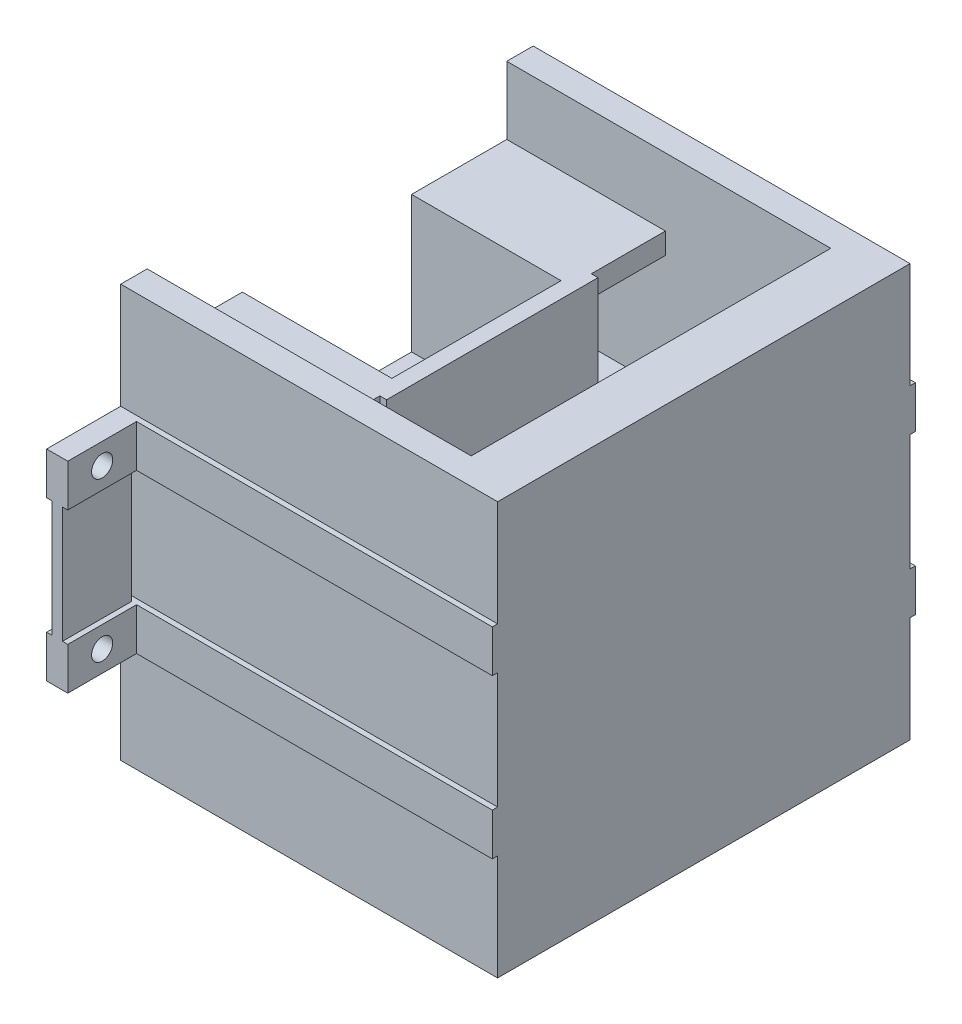
from build123d import *
from build123d.topology import SkipClean

# Parameters (mm, degrees)
SKETCH1_R               = 100
BOSS_EXTRUDE1_DEPTH     = 10
SKETCH2_R               = 95
SKETCH2_R_2             = 80
CUT_EXTRUDE1_DEPTH      = 2
BOSS_EXTRUDE2_DEPTH     = 40
BOSS_EXTRUDE3_DEPTH     = 5
CUT_EXTRUDE2_START      = -5
SKETCH5_W               = 50
SKETCH5_H               = 40
CUT_EXTRUDE2_DEPTH      = 40
BOSS_EXTRUDE4_DEPTH     = 45
SKETCH8_W               = 40
SKETCH8_H               = 5
BOSS_EXTRUDE5_DEPTH     = 55
CUT_EXTRUDE3_START      = -10
SKETCH10_W              = 8.429508811
SKETCH10_H              = 40
CUT_EXTRUDE3_DEPTH      = 10
BOSS_EXTRUDE6_START     = 18.2
BOSS_EXTRUDE6_DEPTH     = 2
BOSS_EXTRUDE7_START     = 18.1
BOSS_EXTRUDE7_DEPTH     = 15
SKETCH13_W              = 20.653307815
SKETCH13_H              = 40
CUT_EXTRUDE4_DEPTH      = 5
BOSS_EXTRUDE8_DEPTH     = 17
BOSS_EXTRUDE9_DEPTH     = 3
BOSS_EXTRUDE10_DEPTH    = 3
SKETCH18_W              = 11.98170237
SKETCH18_H              = 40
CUT_EXTRUDE5_DEPTH      = 5
CUT_EXTRUDE6_START      = -20
CUT_EXTRUDE6_DEPTH      = 25
CUT_EXTRUDE7_DEPTH      = 300
CUT_EXTRUDE7_DEPTH_BACK = 300
BOSS_EXTRUDE12_DEPTH    = 30.7
CUT_EXTRUDE8_DEPTH      = 40
BOSS_EXTRUDE13_START    = -33.64
SKETCH27_W              = 7
SKETCH27_H              = 5
BOSS_EXTRUDE13_DEPTH    = 2
CUT_EXTRUDE9_DEPTH      = 40
F_2_0MM_DOWEL_HOLE2_D   = 2
SKETCH31_W              = 0.5
SKETCH31_H              = 16
CUT_EXTRUDE10_DEPTH     = 12.9
CUT_EXTRUDE11_DEPTH     = 20
SKETCH33_W              = 7
SKETCH33_H              = 2
BOSS_EXTRUDE14_DEPTH    = 15
BOSS_EXTRUDE15_START    = -0.5
SKETCH34_W              = 6.5
SKETCH34_H              = 11
BOSS_EXTRUDE15_DEPTH    = 1
BOSS_EXTRUDE16_DEPTH    = 15.1


with BuildPart() as part:
    # Sketch1 → Boss-Extrude1 (new body)
    with BuildSketch(Plane(origin=(0, 0, 0), x_dir=(1, 0, 0), z_dir=(0, 1, 0))):
        with Locations(Location((0, 0, 0), (0, 0, 270))):
            Circle(SKETCH1_R)
    extrude(amount=BOSS_EXTRUDE1_DEPTH)

    # Sketch2 → Cut-Extrude1 (cut)
    with BuildSketch(Plane(origin=(0, 10, 0), x_dir=(1, 0, 0), z_dir=(0, 1, 0))):
        with Locations(Location((0, 0, 0), (0, 0, 270))):
            Circle(SKETCH2_R)
        with Locations(Location((0, 0, 0), (0, 0, 270))):
            Circle(SKETCH2_R_2, mode=Mode.SUBTRACT)
    extrude(amount=-CUT_EXTRUDE1_DEPTH, mode=Mode.SUBTRACT)

    # Sketch3 → Boss-Extrude2 (add)
    with SkipClean():  # the faces are left unmerged after this step: merging them gives an invalid solid
        with BuildSketch(Plane(origin=(0, 10, 0), x_dir=(1, 0, 0), z_dir=(0, 1, 0))):
            with BuildLine():
                Line((-67.175144213, 67.175144213), (-70.710678119, 70.710678119))
                ThreePointArc((-70.710678119, 70.710678119), (100, 0), (-70.710678119, -70.710678119))
                Line((-70.710678119, -70.710678119), (-67.175144213, -67.175144213))
                ThreePointArc((-67.175144213, -67.175144213), (95, 0), (-67.175144213, 67.175144213))
            make_face()
        extrude(amount=BOSS_EXTRUDE2_DEPTH)

    # Sketch5 → Cut-Extrude2 (cut)
    with SkipClean():  # the faces are left unmerged after this step: merging them gives an invalid solid
        with BuildSketch(Plane(origin=(0, 55, 0), x_dir=(1, 0, 0), z_dir=(0, 1, 0)).offset(CUT_EXTRUDE2_START)):
            with Locations((102.459666924, 0)):
                Rectangle(SKETCH5_W, SKETCH5_H)
        extrude(amount=-CUT_EXTRUDE2_DEPTH, mode=Mode.SUBTRACT)



with BuildPart() as body_2:
    # Sketch4 → Boss-Extrude3 (new body)
    with BuildSketch(Plane(origin=(0, 50, 0), x_dir=(1, 0, 0), z_dir=(0, 1, 0))):
        with BuildLine():
            ThreePointArc((-67.175144213, -67.175144213), (95, 0), (-67.175144213, 67.175144213))
            Line((-67.175144213, 67.175144213), (-56.568542495, 56.568542495))
            ThreePointArc((-56.568542495, 56.568542495), (30.614674589, 73.910362601), (80, 0))
            ThreePointArc((80, 0), (30.614674589, -73.910362601), (-56.568542495, -56.568542495))
            Line((-56.568542495, -56.568542495), (-67.175144213, -67.175144213))
        make_face()
        with BuildLine():
            Line((-70.710678119, 70.710678119), (-67.175144213, 67.175144213))
            ThreePointArc((-67.175144213, 67.175144213), (95, 0), (-67.175144213, -67.175144213))
            Line((-67.175144213, -67.175144213), (-70.710678119, -70.710678119))
            ThreePointArc((-70.710678119, -70.710678119), (100, 0), (-70.710678119, 70.710678119))
        make_face()
    extrude(amount=BOSS_EXTRUDE3_DEPTH)


with BuildPart() as part_1:
    with SkipClean():  # the faces are left unmerged after this step: merging them gives an invalid solid
        add(part.part)

        add(body_2.part)  # Boss-Extrude4 merges body 2
        # Sketch7 → Boss-Extrude4 (add)
        with BuildSketch(Plane(origin=(0, 55, 0), x_dir=(1, 0, 0), z_dir=(0, 1, 0))):
            with BuildLine():
                ThreePointArc((96.824583655, 25), (97.434164903, 22.507410108), (97.979589711, 20))
                Line((97.979589711, 20), (127.459666924, 20))
                Line((127.459666924, 20), (127.459666924, -20))
                Line((127.459666924, -20), (97.979589711, -20))
                ThreePointArc((97.979589711, -20), (97.434164903, -22.507410108), (96.824583655, -25))
                Line((96.824583655, -25), (132.459666924, -25))
                Line((132.459666924, -25), (132.459666924, 25))
                Line((132.459666924, 25), (96.824583655, 25))
            make_face()
        extrude(amount=-BOSS_EXTRUDE4_DEPTH)

    # Sketch8 → Boss-Extrude5 (add)
    with SkipClean():  # the faces are left unmerged after this step: merging them gives an invalid solid
        with BuildSketch(Plane.ZY.offset(-127.459666924)):
            with Locations((0, 12.5)):
                Rectangle(SKETCH8_W, SKETCH8_H)
        extrude(amount=BOSS_EXTRUDE5_DEPTH)

    # Sketch10 → Cut-Extrude3 (cut)
    with SkipClean():  # the faces are left unmerged after this step: merging them gives an invalid solid
        with BuildSketch(Plane.XZ.offset(CUT_EXTRUDE3_START)):
            with Locations((88.6561237, 0)):
                Rectangle(SKETCH10_W, SKETCH10_H)
            with BuildLine():
                Line((92.870878105, -20), (92.870878105, 20))
                ThreePointArc((92.870878105, 20), (95, 0), (92.870878105, -20))
            make_face()
        extrude(amount=-CUT_EXTRUDE3_DEPTH, mode=Mode.SUBTRACT)

    # Sketch13 → Cut-Extrude4 (cut)
    with SkipClean():  # the faces are left unmerged after this step: merging them gives an invalid solid
        with BuildSketch(Plane(origin=(0, 55, 0), x_dir=(1, 0, 0), z_dir=(0, 1, 0))):
            with Locations((100.326653908, 0)):
                Rectangle(SKETCH13_W, SKETCH13_H)
        extrude(amount=-CUT_EXTRUDE4_DEPTH, mode=Mode.SUBTRACT)



with BuildPart() as body_2_2:
    # Sketch11 → Boss-Extrude6 (new body)
    with BuildSketch(Plane(origin=(0, 15, 0), x_dir=(1, 0, 0), z_dir=(0, 1, 0)).offset(BOSS_EXTRUDE6_START)):
        with BuildLine():
            Line((110.459666924, 8), (95.459666924, 8))
            Line((95.459666924, 8), (95.459666924, 3.5))
            Line((95.459666924, 3.5), (100.359666924, 3.5))
            ThreePointArc((100.359666924, 3.5), (103.859666924, 0), (100.359666924, -3.5))
            Line((100.359666924, -3.5), (95.459666924, -3.5))
            Line((95.459666924, -3.5), (95.459666924, -8))
            Line((95.459666924, -8), (110.459666924, -8))
            Line((110.459666924, -8), (110.459666924, 8))
        make_face()
    extrude(amount=BOSS_EXTRUDE6_DEPTH)

    # Sketch12 → Boss-Extrude7 (add)
    with BuildSketch(Plane(origin=(0, 15, 0), x_dir=(1, 0, 0), z_dir=(0, 1, 0)).offset(BOSS_EXTRUDE7_START)):
        Polygon((95.459666924, -10), (95.459666924, -8), (110.459666924, -8), (110.459666924, 8), (95.459666924, 8), (95.459666924, 10), (112.459666924, 10), (112.459666924, -10), align=None)
    extrude(amount=BOSS_EXTRUDE7_DEPTH)


with BuildPart() as part_2:
    with SkipClean():  # the faces are left unmerged after this step: merging them gives an invalid solid
        add(part_1.part)

        add(body_2_2.part)  # Boss-Extrude8 merges body 2 2
        # Sketch15 → Boss-Extrude8 (add)
        with BuildSketch(Plane(origin=(112.459666924, 0, 0), x_dir=(0, 0, -1), z_dir=(1, 0, 0))):
            Polygon((-8.249409199, 33.1), (-18.249409392, 15), (-20, 15), (-20, 15.967177607), (-10, 34.067177257), align=None)
            Polygon((10, 34.067177257), (20, 15.967177607), (20, 15), (18.249409392, 15), (8.249409199, 33.1), align=None)
        extrude(amount=-BOSS_EXTRUDE8_DEPTH)

    # Sketch16 → Boss-Extrude9 (add)
    with BuildSketch(Plane(origin=(0, 0, 0), x_dir=(0.7071067811865464, 0, 0.7071067811865487), z_dir=(-0.7071067811865487, 0, 0.7071067811865464))):
        Polygon((-80, 50), (-95, 35), (-95, 50), align=None)
    extrude(amount=-BOSS_EXTRUDE9_DEPTH)

    # Sketch17 → Boss-Extrude10 (add)
    with BuildSketch(Plane(origin=(0, 0, 0), x_dir=(-0.7071067811865475, 0, 0.7071067811865477), z_dir=(-0.7071067811865477, 0, -0.7071067811865475))):
        Polygon((80, 50), (95, 35), (95, 50), align=None)
    extrude(amount=-BOSS_EXTRUDE10_DEPTH)

    # Sketch18 → Cut-Extrude5 (cut)
    with BuildSketch(Plane(origin=(0, 15, 0), x_dir=(1, 0, 0), z_dir=(0, 1, 0))):
        with Locations((78.450518109, 0)):
            Rectangle(SKETCH18_W, SKETCH18_H)
    extrude(amount=-CUT_EXTRUDE5_DEPTH, mode=Mode.SUBTRACT)

    # Sketch20 → Cut-Extrude6 (cut)
    with BuildSketch(Plane(origin=(0, 55, 0), x_dir=(1, 0, 0), z_dir=(0, 1, 0)).offset(CUT_EXTRUDE6_START)):
        with BuildLine():
            Line((0, 0), (-31.757481462, 118.520534337))
            ThreePointArc((-31.757481462, 118.520534337), (-122.701486088, 0), (-31.757481462, -118.520534337))
            Line((-31.757481462, -118.520534337), (0, 0))
        make_face()
    extrude(amount=-CUT_EXTRUDE6_DEPTH, mode=Mode.SUBTRACT)

    # Sketch21 → Cut-Extrude7 (cut, two sides)
    with BuildSketch(Plane.XY.offset(25)) as cut_extrude7_sk:
        Polygon((100, 0), (100, 10), (96.824583655, 10), (96.824583655, 55), (-129.04485411, 55), (-129.04485411, 0), align=None)
    extrude(amount=CUT_EXTRUDE7_DEPTH, mode=Mode.SUBTRACT)
    extrude(cut_extrude7_sk.sketch, amount=-CUT_EXTRUDE7_DEPTH_BACK, mode=Mode.SUBTRACT)

    # Sketch25 → Boss-Extrude12 (add)
    with BuildSketch(Plane.ZY.offset(-96.824583655)):
        Polygon((-20, 55), (-20, 15), (20, 15), (20, 55), (17, 55), (17, 18), (-17, 18), (-17, 55), align=None)
    extrude(amount=-BOSS_EXTRUDE12_DEPTH)

    # Sketch26 → Cut-Extrude8 (cut)
    with BuildSketch(Plane.ZY.offset(-96.824583655)):
        Polygon((-20, 55), (-20, 15), (20, 15), (20, 55), (25, 55), (25, 10), (-25, 10), (-25, 55), align=None)
    extrude(amount=-CUT_EXTRUDE8_DEPTH, mode=Mode.SUBTRACT)

    # Sketch27 → Boss-Extrude13 (add)
    with BuildSketch(Plane(origin=(132.459666924, 0, 0), x_dir=(0, 0, -1), z_dir=(1, 0, 0)).offset(BOSS_EXTRUDE13_START)):
        with Locations((-23.5, 42.5)):
            Rectangle(SKETCH27_W, SKETCH27_H)
        with Locations((-23.5, 27.5)):
            Rectangle(SKETCH27_W, SKETCH27_H)
        with Locations((23.5, 27.5)):
            Rectangle(SKETCH27_W, SKETCH27_H)
        with Locations((23.5, 42.5)):
            Rectangle(SKETCH27_W, SKETCH27_H)
    extrude(amount=-BOSS_EXTRUDE13_DEPTH)

    # Sketch28 → Cut-Extrude9 (cut)
    with BuildSketch(Plane(origin=(132.459666924, 0, 0), x_dir=(0, 0, -1), z_dir=(1, 0, 0))):
        Polygon((20, 44.5), (20, 45), (20, 55), (-20, 55), (-20, 45), (-20, 44.5), (-19.5, 44.5), (-19.5, 54.5), (19.5, 54.5), (19.5, 44.5), align=None)
        Polygon((-20, 44.5), (-20, 45), (-27, 45), (-27, 40), (-20, 40), (-20, 40.5), (-26.5, 40.5), (-26.5, 44.5), align=None)
        Polygon((-19.5, 40.5), (-20, 40.5), (-20, 40), (-20, 30), (-20, 29.5), (-19.5, 29.5), align=None)
        Polygon((-20, 29.5), (-20, 30), (-27, 30), (-27, 25), (-20, 25), (-20, 25.5), (-26.5, 25.5), (-26.5, 29.5), align=None)
        Polygon((20, 25), (20, 25.5), (19.5, 25.5), (19.5, 15.5), (-19.5, 15.5), (-19.5, 25.5), (-20, 25.5), (-20, 25), (-20, 15), (20, 15), align=None)
        Polygon((27, 30), (20, 30), (20, 29.5), (26.5, 29.5), (26.5, 25.5), (20, 25.5), (20, 25), (27, 25), align=None)
        Polygon((20, 40), (20, 40.5), (19.5, 40.5), (19.5, 29.5), (20, 29.5), (20, 30), align=None)
        Polygon((27, 45), (20, 45), (20, 44.5), (26.5, 44.5), (26.5, 40.5), (20, 40.5), (20, 40), (27, 40), align=None)
    extrude(amount=-CUT_EXTRUDE9_DEPTH, mode=Mode.SUBTRACT)

    # 2.0mm Dowel Hole2 (through all)
    with Locations(Plane(origin=(98.819666924, 0, 0), x_dir=(0, 0, -1), z_dir=(1, 0, 0))):
        with Locations((-23.25, 42.5), (-23.25, 27.5), (23.25, 27.5), (23.25, 42.5)):
            Hole(F_2_0MM_DOWEL_HOLE2_D / 2)

    # Sketch31 → Cut-Extrude10 (cut)
    with BuildSketch(Plane(origin=(0, 48.1, 0), x_dir=(1, 0, 0), z_dir=(0, 1, 0))):
        with Locations((110.709666924, 0)):
            Rectangle(SKETCH31_W, SKETCH31_H)
    extrude(amount=-CUT_EXTRUDE10_DEPTH, mode=Mode.SUBTRACT)

    # Sketch32 → Cut-Extrude11 (cut)
    with BuildSketch(Plane.ZY.offset(-96.824583655)):
        Polygon((-10, 48.1), (-10, 33.1), (10, 33.1), (10, 48.1), (17, 48.1), (17, 18), (-17, 18), (-17, 48.1), align=None)
    extrude(amount=-CUT_EXTRUDE11_DEPTH, mode=Mode.SUBTRACT)


with BuildPart() as cut_extrude11_piece_1:
    # of the separate pieces the step leaves, piece 1, a body of its own (cut_extrude11_pieces)
    add(part_2.part.solids().sort_by_distance((96.824583655, 18, 17))[0])



with BuildPart() as cut_extrude11_piece_2:
    # of the separate pieces the step leaves, piece 2, a body of its own (cut_extrude11_pieces)
    add(part_2.part.solids().sort_by_distance((96.824583655, 33.1, 10))[0])


with BuildPart() as cut_extrude11_piece_1_1:
    add(cut_extrude11_piece_1.part)

    add(cut_extrude11_piece_2.part)  # Boss-Extrude14 merges Cut-Extrude11 piece 2
    # Sketch33 → Boss-Extrude14 (add)
    with BuildSketch(Plane.ZY.offset(-96.824583655)):
        with Locations((-13.5, 47.1)):
            Rectangle(SKETCH33_W, SKETCH33_H)
        with Locations((-13.5, 34.1)):
            Rectangle(SKETCH33_W, SKETCH33_H)
        with Locations((13.5, 47.1)):
            Rectangle(SKETCH33_W, SKETCH33_H)
        with Locations((13.5, 34.1)):
            Rectangle(SKETCH33_W, SKETCH33_H)
    extrude(amount=-BOSS_EXTRUDE14_DEPTH)

    # Sketch34 → Boss-Extrude15 (add)
    with BuildSketch(Plane.ZY.offset(-96.819666924).offset(BOSS_EXTRUDE15_START)):
        with Locations((-23.25, 35)):
            Rectangle(SKETCH34_W, SKETCH34_H)
        with Locations((23.25, 35)):
            Rectangle(SKETCH34_W, SKETCH34_H)
    extrude(amount=-BOSS_EXTRUDE15_DEPTH)

    # Sketch35 → Boss-Extrude16 (add)
    with BuildSketch(Plane.XZ.offset(-33.1)):
        with BuildLine():
            Line((110.03340873, 14.959238822), (98.812214277, 14.959238822))
            Line((98.812214277, 14.959238822), (98.812214277, 9.956701087))
            Line((98.812214277, 9.956701087), (110.924266388, 8.565843429))
            Line((110.924266388, 8.565843429), (110.924266388, -8.652148394))
            Line((110.924266388, -8.652148394), (98.812214277, -10.854339687))
            Line((98.812214277, -10.854339687), (98.812214277, -15.0169624))
            Line((98.812214277, -15.0169624), (110.03340873, -15.0169624))
            ThreePointArc((110.03340873, -15.0169624), (110.53340873, -14.5169624), (110.03340873, -14.0169624))
            Line((110.03340873, -14.0169624), (99.812214277, -14.0169624))
            Line((99.812214277, -14.0169624), (99.812214277, -11.68891604))
            Line((99.812214277, -11.68891604), (111.924266388, -9.486724747))
            Line((111.924266388, -9.486724747), (111.924266388, 9.457582555))
            Line((111.924266388, 9.457582555), (99.812214277, 10.848440214))
            Line((99.812214277, 10.848440214), (99.812214277, 13.959238822))
            Line((99.812214277, 13.959238822), (110.03340873, 13.959238822))
            ThreePointArc((110.03340873, 13.959238822), (110.53340873, 14.459238822), (110.03340873, 14.959238822))
        make_face()
    extrude(amount=BOSS_EXTRUDE16_DEPTH)


solid = cut_extrude11_piece_1_1.part
